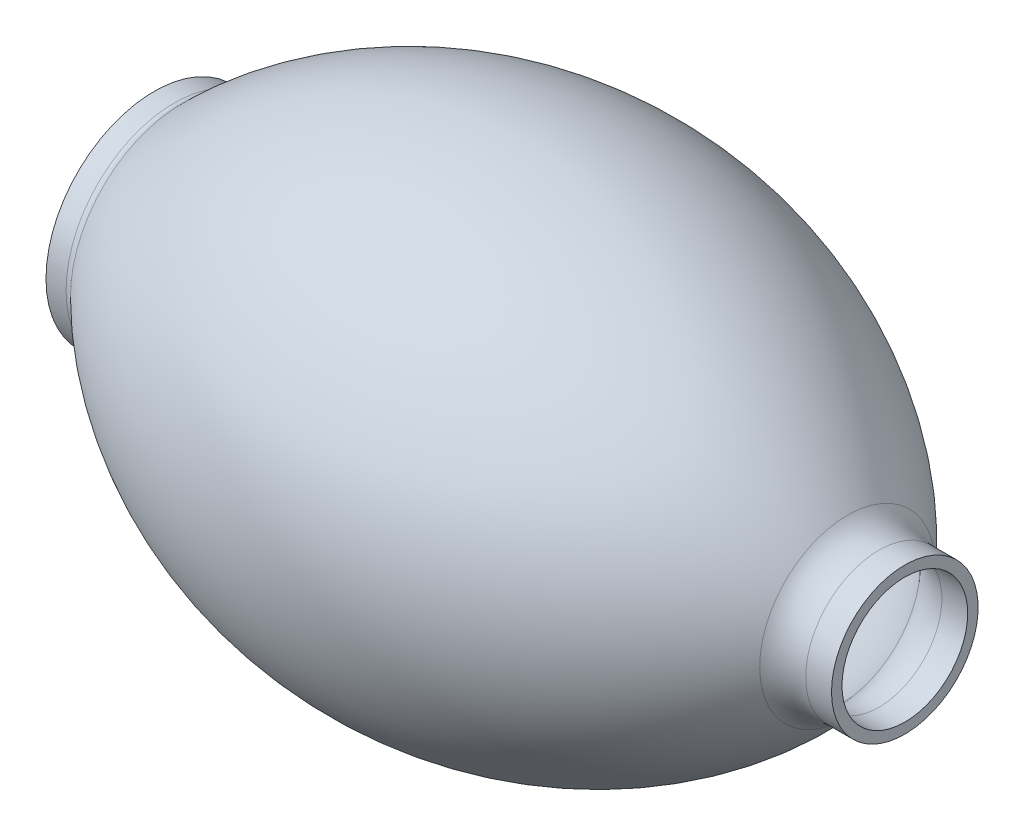
from build123d import *

# Parameters (mm, degrees)
VACIADO1_T = -3


with BuildPart() as part:
    # Croquis2 → Revolución1 (revolve)
    with BuildSketch(Plane.XY, mode=Mode.PRIVATE) as revoluci_n1_sk:
        with BuildLine():
            Line((103.113662929, 21), (110.5, 21))
            Line((110.5, 21), (110.5, 0))
            Line((110.5, 0), (-104.5, 0))
            Line((-104.5, 0), (-104.5, 31))
            Line((-104.5, 31), (-98.748841769, 31))
            ThreePointArc((-98.748841769, 31), (-97.602422314, 31.227686448), (-96.630018974, 31.876185045))
            ThreePointArc((-96.630018974, 31.876185045), (0.180687511, 69.918276225), (94.058838087, 25.125347813))
            ThreePointArc((94.058838087, 25.125347813), (98.138516009, 22.079930718), (103.113662929, 21))
        make_face()
    revolve(revoluci_n1_sk.sketch.rotate(Axis((-104.5, 0, 0), (1, 0, 0)), 90), axis=Axis((-104.5, 0, 0), (1, 0, 0)))

    # Vaciado1
    vaciado1_openings = [part.faces().sort_by_distance(p)[0] for p in [
        (110.5, 0, 0),
        (-104.5, 0, 0),
    ]]
    offset(amount=VACIADO1_T, openings=vaciado1_openings, kind=Kind.INTERSECTION)


solid = part.part
